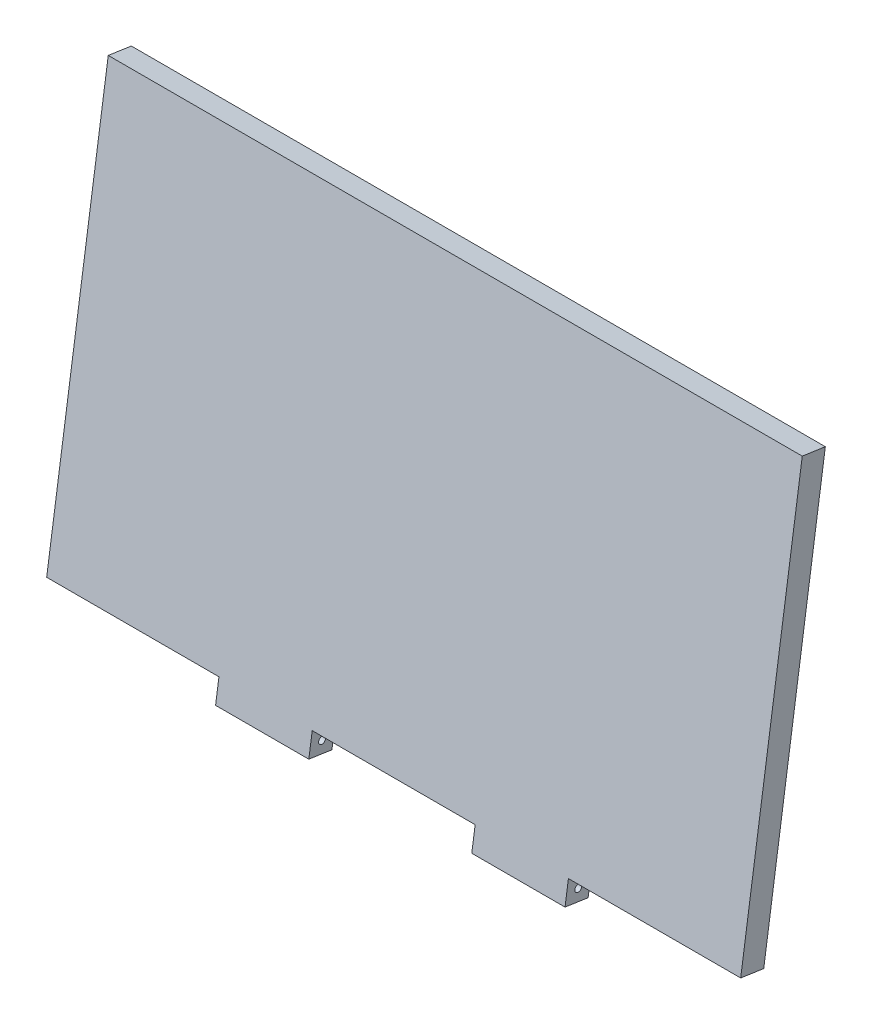
from build123d import *

# Parameters (mm, degrees)
BOSS_EXTRUDE1_DEPTH = 12.7
SKETCH3_R           = 1.904999998
CUT_EXTRUDE1_DEPTH  = 190.34


with BuildPart() as part:
    # Sketch1 → Boss-Extrude1 (new body)
    with BuildSketch(Plane(origin=(0, 21.945100429, 150.12727292), x_dir=(1, 0, 0), z_dir=(0, 0.144646288, 0.989483427))):
        Polygon((-64.482200742, -118.616237813), (29.337799258, -118.616237813), (29.337799258, -131.316237813), (80.137799258, -131.316237813), (80.137799258, -118.616237813), (168.877799258, -118.616237813), (168.877799258, -131.316237813), (219.677799258, -131.316237813), (219.677799258, -118.616237813), (313.497799258, -118.616237813), (313.497799258, 113.205700995), (-64.482200742, 113.205700995), align=None)
    extrude(amount=BOSS_EXTRUDE1_DEPTH)

    # Sketch3 → Cut-Extrude1 (cut)
    with BuildSketch(Plane.ZY.offset(-29.337799258)):
        with Locations((174.48639509, -100.788416836)):
            Circle(SKETCH3_R)
    extrude(amount=-CUT_EXTRUDE1_DEPTH, mode=Mode.SUBTRACT)


solid = part.part
